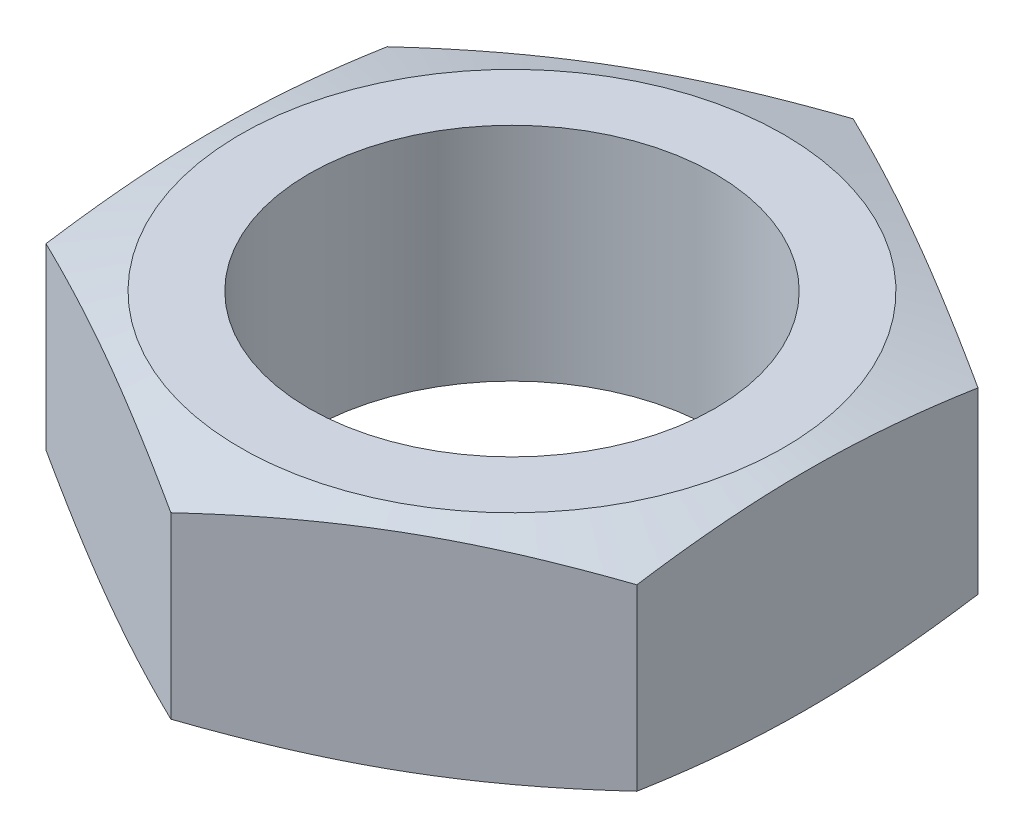
from build123d import *

# Parameters (mm, degrees)
SKETCH1_R           = 2.1828125
BOSS_EXTRUDE1_DEPTH = 2.38125


with BuildPart() as part:
    # Sketch1 → Boss-Extrude1 (new body)
    with BuildSketch(Plane(origin=(0, 0, 0), x_dir=(1, 0, 0), z_dir=(0, 1, 0))):
        Polygon((0, -3.666174209), (3.175, -1.833087105), (3.175, 1.833087105), (0, 3.666174209), (-3.175, 1.833087105), (-3.175, -1.833087105), align=None)
        Circle(SKETCH1_R, mode=Mode.SUBTRACT)
    extrude(amount=BOSS_EXTRUDE1_DEPTH)

    # Sketch2 → Cut-Revolve1 (revolve, cut)
    with BuildSketch(Plane(origin=(0, 0, 0), x_dir=(0, 0, -1), z_dir=(1, 0, 0))):
        Polygon((2.918238424, 2.38125), (3.666174209, 2.151474904), (3.666174209, 2.38125), align=None)
        Polygon((2.918238424, 0), (3.666174209, 0), (3.666174209, 0.229775096), align=None)
    revolve(axis=Axis((0, 0, 0), (0, 1, 0)), mode=Mode.SUBTRACT)


solid = part.part
